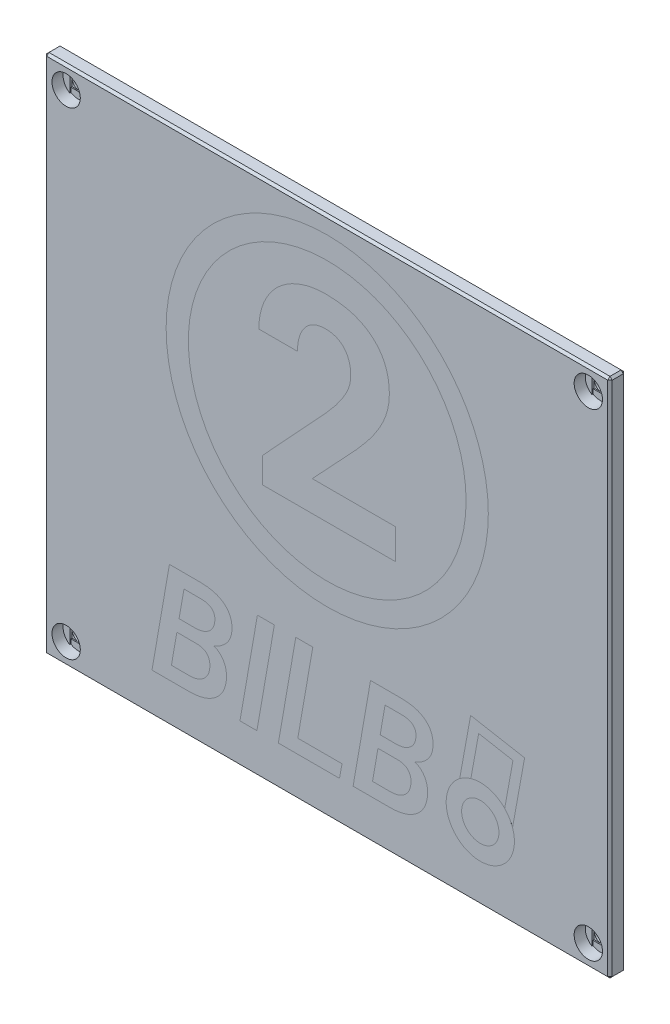
from build123d import *

# Parameters (mm, degrees)
SKETCH2_W               = 101.8
SKETCH2_H               = 93.8
SKETCH2_R               = 1.35
BOSS_EXTRUDE1_DEPTH     = 2.8
SKETCH3_R               = 2.55
CUT_EXTRUDE1_DEPTH      = 2
CUT_EXTRUDE2_DEPTH      = 0.2
SKETCH5_W               = 2.7
SKETCH5_H               = 2.7
CUT_EXTRUDE3_DEPTH      = 0.2
MIRROR2_COPY_1_DEPTH    = 0.2
MIRROR2_COPY_2_SKETCH_W = 2.7
MIRROR2_COPY_2_SKETCH_H = 2.7
MIRROR2_COPY_2_DEPTH    = 0.2
CHAMFER1_SIZE           = 0.4
SKETCH6_W               = 81.8
SKETCH6_H               = 73.8
CUT_EXTRUDE4_DEPTH      = 1.2
SKETCH7_R               = 29
SKETCH7_R_2             = 25
CUT_EXTRUDE5_DEPTH      = 1
SKETCH7_2_R             = 29
SKETCH7_2_R_2           = 25
BOSS_EXTRUDE2_DEPTH     = 1
CUT_EXTRUDE6_DEPTH      = 1
BOSS_EXTRUDE3_DEPTH     = 1
CUT_EXTRUDE7_DEPTH      = 1
BOSS_EXTRUDE4_DEPTH     = 1
BOSS_EXTRUDE4_2_DEPTH   = 1
BOSS_EXTRUDE4_3_DEPTH   = 1
BOSS_EXTRUDE4_4_DEPTH   = 1
BOSS_EXTRUDE4_5_DEPTH   = 1
CUT_EXTRUDE8_DEPTH      = 1
BOSS_EXTRUDE5_DEPTH     = 1


with BuildPart() as part:
    # Sketch2 → Boss-Extrude1 (new body)
    with BuildSketch(Plane.XY):
        with Locations((0, -6)):
            Rectangle(SKETCH2_W, SKETCH2_H)
        with Locations((-47, 37)):
            Circle(SKETCH2_R, mode=Mode.SUBTRACT)
        with Locations((47, 37)):
            Circle(SKETCH2_R, mode=Mode.SUBTRACT)
        with Locations((47, -49)):
            Circle(SKETCH2_R, mode=Mode.SUBTRACT)
        with Locations((-47, -49)):
            Circle(SKETCH2_R, mode=Mode.SUBTRACT)
    extrude(amount=BOSS_EXTRUDE1_DEPTH)

    # Sketch3 → Cut-Extrude1 (cut)
    with BuildSketch(Plane.XY.offset(2.8)):
        with Locations((-47, 37)):
            Circle(SKETCH3_R)
        with Locations((47, 37)):
            Circle(SKETCH3_R)
        with Locations((47, -49)):
            Circle(SKETCH3_R)
        with Locations((-47, -49)):
            Circle(SKETCH3_R)
    extrude(amount=-CUT_EXTRUDE1_DEPTH, mode=Mode.SUBTRACT)

    # Sketch4 → Cut-Extrude2 (cut)
    with BuildSketch(Plane.XY.offset(0.8)):
        with BuildLine():
            Line((-48.35, 34.836669235), (-48.35, 39.163330765))
            ThreePointArc((-48.35, 39.163330765), (-47, 39.55), (-45.65, 39.163330765))
            Line((-45.65, 39.163330765), (-45.65, 34.836669235))
            ThreePointArc((-45.65, 34.836669235), (-47, 34.45), (-48.35, 34.836669235))
        make_face()
    cut_extrude2 = extrude(amount=-CUT_EXTRUDE2_DEPTH, mode=Mode.SUBTRACT)

    # Sketch5 → Cut-Extrude3 (cut)
    with BuildSketch(Plane.XY.offset(0.6)):
        with Locations((-47, 37)):
            Rectangle(SKETCH5_W, SKETCH5_H)
    cut_extrude3 = extrude(amount=-CUT_EXTRUDE3_DEPTH, mode=Mode.SUBTRACT)

    # Mirror1: Cut-Extrude2, Cut-Extrude3 across plane
    add(cut_extrude2.mirror(Plane.ZX.offset(-6)), mode=Mode.SUBTRACT)
    add(cut_extrude3.mirror(Plane.ZX.offset(-6)), mode=Mode.SUBTRACT)

    # Mirror2: Cut-Extrude2, Cut-Extrude3 across plane
    add(cut_extrude2.mirror(Plane(origin=(0, 0, 0), x_dir=(0, 0, 1), z_dir=(1, 0, 0))), mode=Mode.SUBTRACT)
    add(cut_extrude3.mirror(Plane(origin=(0, 0, 0), x_dir=(0, 0, 1), z_dir=(1, 0, 0))), mode=Mode.SUBTRACT)

    # Mirror2 copy 1 sketch → Mirror2 copy 1 (cut)
    with BuildSketch(Plane(origin=(0, -12, 0.8), x_dir=(-1, 0, 0), z_dir=(0, 0, 1))):
        with BuildLine():
            Line((-48.35, 34.836669235), (-48.35, 39.163330765))
            ThreePointArc((-48.35, 39.163330765), (-47, 39.55), (-45.65, 39.163330765))
            Line((-45.65, 39.163330765), (-45.65, 34.836669235))
            ThreePointArc((-45.65, 34.836669235), (-47, 34.45), (-48.35, 34.836669235))
        make_face()
    extrude(amount=-MIRROR2_COPY_1_DEPTH, mode=Mode.SUBTRACT)

    # Mirror2 copy 2 sketch → Mirror2 copy 2 (cut)
    with BuildSketch(Plane(origin=(0, -12, 0.6), x_dir=(-1, 0, 0), z_dir=(0, 0, 1))):
        with Locations((-47, 37)):
            Rectangle(MIRROR2_COPY_2_SKETCH_W, MIRROR2_COPY_2_SKETCH_H)
    extrude(amount=-MIRROR2_COPY_2_DEPTH, mode=Mode.SUBTRACT)

    # Chamfer1
    chamfer1_edges = [part.edges().sort_by_distance(p)[0] for p in [
        (50.9, -6, 2.8),
        (0, 40.9, 2.8),
        (-50.9, -6, 2.8),
        (0, 40.9, 0),
        (50.9, -6, 0),
        (0, -52.9, 0),
        (-50.9, -6, 0),
        (-50.9, 40.9, 1.4),
        (50.9, 40.9, 1.4),
        (50.9, -52.9, 1.4),
        (-50.9, -52.9, 1.4),
        (0, -52.9, 2.8),
    ]]
    chamfer(chamfer1_edges, length=CHAMFER1_SIZE)

    # Sketch6 → Cut-Extrude4 (cut)
    with BuildSketch(Plane(origin=(0, 0, 0), x_dir=(-1, 0, 0), z_dir=(0, 0, -1))):
        with Locations((0, -6)):
            Rectangle(SKETCH6_W, SKETCH6_H)
    extrude(amount=-CUT_EXTRUDE4_DEPTH, mode=Mode.SUBTRACT)

    # Sketch7 → Cut-Extrude5 (cut)
    with BuildSketch(Plane.XY.offset(2.8)):
        with Locations((0, 8.9)):
            Circle(SKETCH7_R)
        with Locations((0, 8.9)):
            Circle(SKETCH7_R_2, mode=Mode.SUBTRACT)
    extrude(amount=-CUT_EXTRUDE5_DEPTH, mode=Mode.SUBTRACT)

    # Sketch8 → Cut-Extrude6 (cut)
    with BuildSketch(Plane.XY.offset(2.8)):
        with BuildLine():
            Line((12.308806818, -6.9), (-11.611647727, -6.9))
            Line((-11.611647727, -6.9), (-11.611647727, -2.262215909))
            Line((-11.611647727, -2.262215909), (-0.319034091, 9.911079545))
            add(Edge.make_bspline(
                [(-0.319034091, 9.911079545), (0.046385124, 10.32500147), (0.741681077, 11.112585228), (1.681474188, 12.275609102), (2.469340925, 13.357130302), (3.111098177, 14.364459395), (3.617475219, 15.319007899), (3.969715632, 16.24865266), (4.187704616, 17.157189298), (4.218527997, 17.758004133), (4.233522727, 18.050284091)],
                knots=[0, 0, 0, 0, 0.001656292, 0.003151485, 0.004484065, 0.005668293, 0.00673245, 0.007719155, 0.00864436, 0.009520822, 0.009520822, 0.009520822, 0.009520822], degree=3))
            add(Edge.make_bspline(
                [(4.233522727, 18.050284091), (4.222002767, 18.42320379), (4.200054171, 19.133715287), (3.977941185, 20.137075527), (3.608226076, 21.018906979), (3.164221923, 21.642288746), (2.758902446, 22.077096009), (2.410135775, 22.348210778), (2.035921266, 22.580076326), (1.6321501, 22.780598295), (1.191202102, 22.913676881), (0.724841328, 23.025059029), (0.224832259, 23.088452989), (-0.1200019, 23.096072798), (-0.297727273, 23.1)],
                knots=[0, 0, 0, 0, 0.001117316, 0.002128786, 0.003064158, 0.003966594, 0.00440865, 0.004843457, 0.00528688, 0.005728423, 0.006191107, 0.006664888, 0.007166139, 0.007699236, 0.007699236, 0.007699236, 0.007699236], degree=3))
            add(Edge.make_bspline(
                [(-0.297727273, 23.1), (-0.489778706, 23.094385488), (-0.863682605, 23.083454626), (-1.408489781, 23.002941766), (-1.920810873, 22.876850677), (-2.403503345, 22.69835886), (-2.854738269, 22.462192091), (-3.271175119, 22.169541221), (-3.662387192, 21.832033134), (-4.013594205, 21.440489579), (-4.333002485, 21.011649874), (-4.602618823, 20.541839399), (-4.841809345, 20.046130428), (-5.020342245, 19.509427426), (-5.173712915, 18.946058662), (-5.277163903, 18.349272526), (-5.343293328, 17.720343597), (-5.350732051, 17.290517497), (-5.354545455, 17.070170455)],
                knots=[0, 0, 0, 0, 0.000575985, 0.001121382, 0.001648484, 0.002156383, 0.002661494, 0.003171772, 0.003680217, 0.004208131, 0.004746501, 0.00528125, 0.005830885, 0.006394656, 0.00697522, 0.007581248, 0.008209509, 0.008870364, 0.008870364, 0.008870364, 0.008870364], degree=3))
            Line((-5.354545455, 17.070170455), (-12.307670455, 17.070170455))
            add(Edge.make_bspline(
                [(-12.307670455, 17.070170455), (-12.291892712, 17.592522347), (-12.260726492, 18.624338799), (-11.953970118, 20.128962544), (-11.487523274, 21.570135071), (-10.817776605, 22.924881667), (-9.97300169, 24.172944223), (-8.972231012, 25.298301174), (-7.797179901, 26.258148805), (-6.712136052, 26.944918404), (-5.777702784, 27.411834126), (-5.044661786, 27.718673693), (-4.288714461, 27.972316034), (-3.512263707, 28.189488487), (-2.709089407, 28.348786663), (-1.884618269, 28.471480562), (-1.037679487, 28.543992965), (-0.465951481, 28.551002629), (-0.176988636, 28.554545455)],
                knots=[0, 0, 0, 0, 0.001565226, 0.003091834, 0.004587634, 0.006099551, 0.007608462, 0.009097164, 0.010600331, 0.012145169, 0.012939227, 0.01373195, 0.014527024, 0.015329958, 0.016148971, 0.016981635, 0.017829784, 0.018696523, 0.018696523, 0.018696523, 0.018696523], degree=3))
            add(Edge.make_bspline(
                [(-0.176988636, 28.554545455), (0.258925877, 28.546352483), (1.108806637, 28.530379055), (2.347484714, 28.406672953), (3.512675121, 28.214264157), (4.601684716, 27.928949402), (5.613934271, 27.558475211), (6.554840249, 27.111834904), (7.422759809, 26.585655483), (8.203914583, 25.969826424), (8.910609806, 25.292365062), (9.519195393, 24.535587481), (10.041143009, 23.718513297), (10.462215987, 22.827474445), (10.78758639, 21.871560544), (11.022980896, 20.851075432), (11.156237975, 19.763087063), (11.176320755, 19.016553262), (11.186647727, 18.632670455)],
                knots=[0, 0, 0, 0, 0.001307513, 0.002549192, 0.003730819, 0.004847119, 0.005921137, 0.00695994, 0.007967287, 0.008958964, 0.009938382, 0.010897846, 0.011865269, 0.012840558, 0.013846778, 0.014889095, 0.015977042, 0.017128684, 0.017128684, 0.017128684, 0.017128684], degree=3))
            add(Edge.make_bspline(
                [(11.186647727, 18.632670455), (11.169260049, 18.198312911), (11.13402119, 17.318019213), (10.872737149, 15.994364547), (10.450398039, 14.658487031), (9.955762844, 13.549073246), (9.479460404, 12.639803325), (9.051740032, 11.922054404), (8.55818677, 11.18115744), (8.020779633, 10.399624193), (7.405931285, 9.604753552), (6.744134003, 8.768513978), (6.023338248, 7.902993521), (5.506777755, 7.328884474), (5.242045455, 7.034659091)],
                knots=[0, 0, 0, 0, 0.001302507, 0.002639735, 0.004032397, 0.005498461, 0.0062768, 0.007111159, 0.008003505, 0.008947252, 0.0099558, 0.011017299, 0.012146717, 0.013334008, 0.013334008, 0.013334008, 0.013334008], degree=3))
            Line((5.242045455, 7.034659091), (-2.691193182, -1.445454545))
            Line((-2.691193182, -1.445454545), (12.308806818, -1.445454545))
            Line((12.308806818, -1.445454545), (12.308806818, -6.9))
        make_face()
    extrude(amount=-CUT_EXTRUDE6_DEPTH, mode=Mode.SUBTRACT)

    # Sketch9 → Cut-Extrude7 (cut)
    with BuildSketch(Plane.XY.offset(2.8)):
        with BuildLine():
            add(Edge.make_bspline(
                [(-20.133559814, -44.28194528), (-21.340720814, -45.24106528), (-22.936488814, -45.72062528), (-24.920863814, -45.72062528)],
                knots=[0, 0, 0, 0, 1, 1, 1, 1], degree=3))
            Line((-24.920863814, -45.72062528), (-31.543715814, -45.72062728))
            Line((-31.543715814, -45.72062728), (-28.405922814, -27.66281228))
            Line((-28.405922814, -27.66281228), (-22.862074814, -27.67521228))
            add(Edge.make_bspline(
                [(-22.862074814, -27.67521228), (-20.910772814, -27.68347928), (-19.447296814, -28.10929228), (-18.471645814, -28.95265328)],
                knots=[0, 0, 0, 0, 1, 1, 1, 1], degree=3))
            add(Edge.make_bspline(
                [(-18.471645814, -28.95265328), (-17.487726814, -29.78774428), (-17.053644814, -30.94943228), (-17.169399814, -32.43771528)],
                knots=[0, 0, 0, 0, 1, 1, 1, 1], degree=3))
            add(Edge.make_bspline(
                [(-17.169399814, -32.43771528), (-17.318227814, -34.19057528), (-18.388963814, -35.50935528), (-20.381606814, -36.39405528)],
                knots=[0, 0, 0, 0, 1, 1, 1, 1], degree=3))
            add(Edge.make_bspline(
                [(-20.381606814, -36.39405528), (-19.637465814, -36.65864228), (-19.062823814, -37.14233528), (-18.657680814, -37.84513528)],
                knots=[0, 0, 0, 0, 1, 1, 1, 1], degree=3))
            add(Edge.make_bspline(
                [(-18.657680814, -37.84513528), (-18.252537814, -38.54793528), (-18.078904814, -39.38715828), (-18.136782814, -40.36280528)],
                knots=[0, 0, 0, 0, 1, 1, 1, 1], degree=3))
            add(Edge.make_bspline(
                [(-18.136782814, -40.36280528), (-18.252537814, -42.01645228), (-18.918129814, -43.32283228), (-20.133559814, -44.28194528)],
                knots=[0, 0, 0, 0, 1, 1, 1, 1], degree=3))
        make_face()
        with BuildLine():
            add(Edge.make_bspline(
                [(-20.257582814, -32.61134728), (-20.050877814, -31.06518828), (-20.832224814, -30.26316928), (-22.601625814, -30.20529228)],
                knots=[0, 0, 0, 0, 1, 1, 1, 1], degree=3))
            Line((-22.601625814, -30.20529228), (-25.789028814, -30.19289228))
            Line((-25.789028814, -30.19289228), (-26.669594814, -35.26544728))
            Line((-26.669594814, -35.26544728), (-23.854262814, -35.27784728))
            add(Edge.make_bspline(
                [(-23.854262814, -35.27784728), (-22.845538814, -35.27784728), (-22.022849814, -35.03807028), (-21.386196814, -34.55851728)],
                knots=[0, 0, 0, 0, 1, 1, 1, 1], degree=3))
            add(Edge.make_bspline(
                [(-21.386196814, -34.55851728), (-20.749542814, -34.07895728), (-20.373337814, -33.42990028), (-20.257582814, -32.61134728)],
                knots=[0, 0, 0, 0, 1, 1, 1, 1], degree=3))
        make_face(mode=Mode.SUBTRACT)
        with BuildLine():
            add(Edge.make_bspline(
                [(-21.547426814, -38.35361728), (-21.919497814, -37.87406428), (-22.535480814, -37.61775028), (-23.395375814, -37.58467728)],
                knots=[0, 0, 0, 0, 1, 1, 1, 1], degree=3))
            Line((-23.395375814, -37.58467728), (-27.066469814, -37.57228728))
            Line((-27.066469814, -37.57228728), (-28.046254814, -43.21534728))
            Line((-28.046254814, -43.21534728), (-24.834047814, -43.22774728))
            add(Edge.make_bspline(
                [(-24.834047814, -43.22774728), (-23.866664814, -43.22774728), (-23.043976814, -42.97143028), (-22.365981814, -42.45879728)],
                knots=[0, 0, 0, 0, 1, 1, 1, 1], degree=3))
            add(Edge.make_bspline(
                [(-22.365981814, -42.45879728), (-21.687986814, -41.94617028), (-21.286977814, -41.24337028), (-21.162953814, -40.35039728)],
                knots=[0, 0, 0, 0, 1, 1, 1, 1], degree=3))
            add(Edge.make_bspline(
                [(-21.162953814, -40.35039728), (-21.047198814, -39.49877028), (-21.175356814, -38.83317728), (-21.547426814, -38.35361728)],
                knots=[0, 0, 0, 0, 1, 1, 1, 1], degree=3))
        make_face(mode=Mode.SUBTRACT)
        Polygon((-9.517153814, -27.66281228), (-12.654946814, -45.72062728), (-15.705922814, -45.72062728), (-12.568129814, -27.66281228), align=None)
        Polygon((-2.596648814, -27.66281228), (-5.300358814, -43.21534728), (2.661951186, -43.21534728), (2.215461186, -45.72062728), (-8.797818814, -45.72062728), (-5.660028814, -27.66281228), align=None)
        with BuildLine():
            add(Edge.make_bspline(
                [(16.068881186, -44.28194528), (14.861721186, -45.24106528), (13.265954186, -45.72062528), (11.281581186, -45.72062528)],
                knots=[0, 0, 0, 0, 1, 1, 1, 1], degree=3))
            Line((11.281581186, -45.72062528), (4.658731186, -45.72062728))
            Line((4.658731186, -45.72062728), (7.796521186, -27.66281228))
            Line((7.796521186, -27.66281228), (13.340371186, -27.67521228))
            add(Edge.make_bspline(
                [(13.340371186, -27.67521228), (15.291671186, -27.68347928), (16.755148186, -28.10929228), (17.730801186, -28.95265328)],
                knots=[0, 0, 0, 0, 1, 1, 1, 1], degree=3))
            add(Edge.make_bspline(
                [(17.730801186, -28.95265328), (18.714714186, -29.78774428), (19.148794186, -30.94943228), (19.033041186, -32.43771528)],
                knots=[0, 0, 0, 0, 1, 1, 1, 1], degree=3))
            add(Edge.make_bspline(
                [(19.033041186, -32.43771528), (18.884214186, -34.19057528), (17.813478186, -35.50935528), (15.820831186, -36.39405528)],
                knots=[0, 0, 0, 0, 1, 1, 1, 1], degree=3))
            add(Edge.make_bspline(
                [(15.820831186, -36.39405528), (16.564978186, -36.65864228), (17.139621186, -37.14233528), (17.544761186, -37.84513528)],
                knots=[0, 0, 0, 0, 1, 1, 1, 1], degree=3))
            add(Edge.make_bspline(
                [(17.544761186, -37.84513528), (17.949908186, -38.54793528), (18.123541186, -39.38715828), (18.065661186, -40.36280528)],
                knots=[0, 0, 0, 0, 1, 1, 1, 1], degree=3))
            add(Edge.make_bspline(
                [(18.065661186, -40.36280528), (17.949908186, -42.01645228), (17.284314186, -43.32283228), (16.068881186, -44.28194528)],
                knots=[0, 0, 0, 0, 1, 1, 1, 1], degree=3))
        make_face()
        with BuildLine():
            add(Edge.make_bspline(
                [(15.944861186, -32.61134728), (16.151568186, -31.06518828), (15.370218186, -30.26316928), (13.600811186, -30.20529228)],
                knots=[0, 0, 0, 0, 1, 1, 1, 1], degree=3))
            Line((13.600811186, -30.20529228), (10.413411186, -30.19289228))
            Line((10.413411186, -30.19289228), (9.532851186, -35.26544728))
            Line((9.532851186, -35.26544728), (12.348181186, -35.27784728))
            add(Edge.make_bspline(
                [(12.348181186, -35.27784728), (13.356901186, -35.27784728), (14.179588186, -35.03807028), (14.816241186, -34.55851728)],
                knots=[0, 0, 0, 0, 1, 1, 1, 1], degree=3))
            add(Edge.make_bspline(
                [(14.816241186, -34.55851728), (15.452901186, -34.07895728), (15.829108186, -33.42990028), (15.944861186, -32.61134728)],
                knots=[0, 0, 0, 0, 1, 1, 1, 1], degree=3))
        make_face(mode=Mode.SUBTRACT)
        with BuildLine():
            add(Edge.make_bspline(
                [(14.655011186, -38.35361728), (14.282944186, -37.87406428), (13.666961186, -37.61775028), (12.807061186, -37.58467728)],
                knots=[0, 0, 0, 0, 1, 1, 1, 1], degree=3))
            Line((12.807061186, -37.58467728), (9.135971186, -37.57228728))
            Line((9.135971186, -37.57228728), (8.156191186, -43.21534728))
            Line((8.156191186, -43.21534728), (11.368391186, -43.22774728))
            add(Edge.make_bspline(
                [(11.368391186, -43.22774728), (12.335778186, -43.22774728), (13.158468186, -42.97143028), (13.836461186, -42.45879728)],
                knots=[0, 0, 0, 0, 1, 1, 1, 1], degree=3))
            add(Edge.make_bspline(
                [(13.836461186, -42.45879728), (14.514454186, -41.94617028), (14.915464186, -41.24337028), (15.039491186, -40.35039728)],
                knots=[0, 0, 0, 0, 1, 1, 1, 1], degree=3))
            add(Edge.make_bspline(
                [(15.039491186, -40.35039728), (15.155244186, -39.49877028), (15.027084186, -38.83317728), (14.655011186, -38.35361728)],
                knots=[0, 0, 0, 0, 1, 1, 1, 1], degree=3))
        make_face(mode=Mode.SUBTRACT)
        with BuildLine():
            add(Edge.make_bspline(
                [(33.697238186, -39.82961728), (33.697238186, -38.20072528), (33.050162186, -36.63854728), (31.898362186, -35.48674628)],
                knots=[0, 0, 0, 0, 1, 1, 1, 1], degree=3))
            add(Edge.make_bspline(
                [(31.898362186, -35.48674628), (30.746561186, -34.33494628), (29.184383186, -33.68787028), (27.555491186, -33.68787028)],
                knots=[0, 0, 0, 0, 1, 1, 1, 1], degree=3))
            add(Edge.make_bspline(
                [(27.555491186, -33.68787028), (25.071386186, -33.68787028), (22.831883186, -35.18425928), (21.881257186, -37.47927228)],
                knots=[0, 0, 0, 0, 1, 1, 1, 1], degree=3))
            add(Edge.make_bspline(
                [(21.881257186, -37.47927228), (20.930631186, -39.77428628), (21.456093186, -42.41596028), (23.212620186, -44.17248828)],
                knots=[0, 0, 0, 0, 1, 1, 1, 1], degree=3))
            add(Edge.make_bspline(
                [(23.212620186, -44.17248828), (24.969148186, -45.92901528), (27.610822186, -46.45447728), (29.905836186, -45.50385128)],
                knots=[0, 0, 0, 0, 1, 1, 1, 1], degree=3))
            add(Edge.make_bspline(
                [(29.905836186, -45.50385128), (32.200849186, -44.55322528), (33.697238186, -42.31372228), (33.697238186, -39.82961728)],
                knots=[0, 0, 0, 0, 1, 1, 1, 1], degree=3))
        make_face()
        with BuildLine():
            add(Edge.make_bspline(
                [(29.932660186, -37.45244828), (29.302195186, -36.82198428), (28.447102186, -36.46779328), (27.555491186, -36.46779328)],
                knots=[0, 0, 0, 0, 1, 1, 1, 1], degree=3))
            add(Edge.make_bspline(
                [(27.555491186, -36.46779328), (26.195760186, -36.46779328), (24.969917186, -37.28687528), (24.449570186, -38.54310328)],
                knots=[0, 0, 0, 0, 1, 1, 1, 1], degree=3))
            add(Edge.make_bspline(
                [(24.449570186, -38.54310328), (23.929224186, -39.79933028), (24.216847186, -41.24531128), (25.178322186, -42.20678628)],
                knots=[0, 0, 0, 0, 1, 1, 1, 1], degree=3))
            add(Edge.make_bspline(
                [(25.178322186, -42.20678628), (26.139797186, -43.16826128), (27.585778186, -43.45588428), (28.842005186, -42.93553828)],
                knots=[0, 0, 0, 0, 1, 1, 1, 1], degree=3))
            add(Edge.make_bspline(
                [(28.842005186, -42.93553828), (30.098233186, -42.41519128), (30.917315186, -41.18934828), (30.917315186, -39.82961728)],
                knots=[0, 0, 0, 0, 1, 1, 1, 1], degree=3))
            add(Edge.make_bspline(
                [(30.917315186, -39.82961728), (30.917315186, -38.93800628), (30.563124186, -38.08291328), (29.932660186, -37.45244828)],
                knots=[0, 0, 0, 0, 1, 1, 1, 1], degree=3))
        make_face(mode=Mode.SUBTRACT)
    extrude(amount=-CUT_EXTRUDE7_DEPTH, mode=Mode.SUBTRACT)

    # Sketch10 → Cut-Extrude8 (cut)
    with BuildSketch(Plane.XY.offset(2.8)):
        with BuildLine():
            Line((35.529593186, -25.86224928), (33.361742565, -37.827481777))
            add(Edge.make_bspline(
                [(33.361742565, -37.827481777), (33.068142523, -36.976090582), (32.588251207, -36.191936535), (31.94752174, -35.536467995)],
                knots=[0.422314756, 0.422314756, 0.422314756, 0.422314756, 0.985683182, 0.985683182, 0.985683182, 0.985683182], degree=3))
            Line((31.94752174, -35.536467995), (33.43753038, -27.312515835))
            Line((33.43753038, -27.312515835), (27.262743774, -26.19377313))
            Line((27.262743774, -26.19377313), (25.861881169, -33.92569283))
            add(Edge.make_bspline(
                [(25.861881169, -33.92569283), (25.131570387, -34.13524271), (24.450098636, -34.477778089), (23.850380245, -34.931306228)],
                knots=[0.234479883, 0.234479883, 0.234479883, 0.234479883, 0.550360789, 0.550360789, 0.550360789, 0.550360789], degree=3))
            Line((23.850380245, -34.931306228), (25.812477186, -24.10171028))
            Line((25.812477186, -24.10171028), (35.529593186, -25.86224928))
        make_face()
    extrude(amount=-CUT_EXTRUDE8_DEPTH, mode=Mode.SUBTRACT)


with BuildPart() as body_2:
    # Sketch7_2 → Boss-Extrude2 (new body)
    with BuildSketch(Plane.XY.offset(2.8)):
        with Locations((0, 8.9)):
            Circle(SKETCH7_2_R)
        with Locations((0, 8.9)):
            Circle(SKETCH7_2_R_2, mode=Mode.SUBTRACT)
    extrude(amount=-BOSS_EXTRUDE2_DEPTH)


with BuildPart() as body_3:
    # Sketch8_2 → Boss-Extrude3 (new body)
    with BuildSketch(Plane.XY.offset(2.8)):
        with BuildLine():
            Line((12.308806818, -6.9), (-11.611647727, -6.9))
            Line((-11.611647727, -6.9), (-11.611647727, -2.262215909))
            Line((-11.611647727, -2.262215909), (-0.319034091, 9.911079545))
            add(Edge.make_bspline(
                [(-0.319034091, 9.911079545), (0.046385124, 10.32500147), (0.741681077, 11.112585228), (1.681474188, 12.275609102), (2.469340925, 13.357130302), (3.111098177, 14.364459395), (3.617475219, 15.319007899), (3.969715632, 16.24865266), (4.187704616, 17.157189298), (4.218527997, 17.758004133), (4.233522727, 18.050284091)],
                knots=[0, 0, 0, 0, 0.001656292, 0.003151485, 0.004484065, 0.005668293, 0.00673245, 0.007719155, 0.00864436, 0.009520822, 0.009520822, 0.009520822, 0.009520822], degree=3))
            add(Edge.make_bspline(
                [(4.233522727, 18.050284091), (4.222002767, 18.42320379), (4.200054171, 19.133715287), (3.977941185, 20.137075527), (3.608226076, 21.018906979), (3.164221923, 21.642288746), (2.758902446, 22.077096009), (2.410135775, 22.348210778), (2.035921266, 22.580076326), (1.6321501, 22.780598295), (1.191202102, 22.913676881), (0.724841328, 23.025059029), (0.224832259, 23.088452989), (-0.1200019, 23.096072798), (-0.297727273, 23.1)],
                knots=[0, 0, 0, 0, 0.001117316, 0.002128786, 0.003064158, 0.003966594, 0.00440865, 0.004843457, 0.00528688, 0.005728423, 0.006191107, 0.006664888, 0.007166139, 0.007699236, 0.007699236, 0.007699236, 0.007699236], degree=3))
            add(Edge.make_bspline(
                [(-0.297727273, 23.1), (-0.489778706, 23.094385488), (-0.863682605, 23.083454626), (-1.408489781, 23.002941766), (-1.920810873, 22.876850677), (-2.403503345, 22.69835886), (-2.854738269, 22.462192091), (-3.271175119, 22.169541221), (-3.662387192, 21.832033134), (-4.013594205, 21.440489579), (-4.333002485, 21.011649874), (-4.602618823, 20.541839399), (-4.841809345, 20.046130428), (-5.020342245, 19.509427426), (-5.173712915, 18.946058662), (-5.277163903, 18.349272526), (-5.343293328, 17.720343597), (-5.350732051, 17.290517497), (-5.354545455, 17.070170455)],
                knots=[0, 0, 0, 0, 0.000575985, 0.001121382, 0.001648484, 0.002156383, 0.002661494, 0.003171772, 0.003680217, 0.004208131, 0.004746501, 0.00528125, 0.005830885, 0.006394656, 0.00697522, 0.007581248, 0.008209509, 0.008870364, 0.008870364, 0.008870364, 0.008870364], degree=3))
            Line((-5.354545455, 17.070170455), (-12.307670455, 17.070170455))
            add(Edge.make_bspline(
                [(-12.307670455, 17.070170455), (-12.291892712, 17.592522347), (-12.260726492, 18.624338799), (-11.953970118, 20.128962544), (-11.487523274, 21.570135071), (-10.817776605, 22.924881667), (-9.97300169, 24.172944223), (-8.972231012, 25.298301174), (-7.797179901, 26.258148805), (-6.712136052, 26.944918404), (-5.777702784, 27.411834126), (-5.044661786, 27.718673693), (-4.288714461, 27.972316034), (-3.512263707, 28.189488487), (-2.709089407, 28.348786663), (-1.884618269, 28.471480562), (-1.037679487, 28.543992965), (-0.465951481, 28.551002629), (-0.176988636, 28.554545455)],
                knots=[0, 0, 0, 0, 0.001565226, 0.003091834, 0.004587634, 0.006099551, 0.007608462, 0.009097164, 0.010600331, 0.012145169, 0.012939227, 0.01373195, 0.014527024, 0.015329958, 0.016148971, 0.016981635, 0.017829784, 0.018696523, 0.018696523, 0.018696523, 0.018696523], degree=3))
            add(Edge.make_bspline(
                [(-0.176988636, 28.554545455), (0.258925877, 28.546352483), (1.108806637, 28.530379055), (2.347484714, 28.406672953), (3.512675121, 28.214264157), (4.601684716, 27.928949402), (5.613934271, 27.558475211), (6.554840249, 27.111834904), (7.422759809, 26.585655483), (8.203914583, 25.969826424), (8.910609806, 25.292365062), (9.519195393, 24.535587481), (10.041143009, 23.718513297), (10.462215987, 22.827474445), (10.78758639, 21.871560544), (11.022980896, 20.851075432), (11.156237975, 19.763087063), (11.176320755, 19.016553262), (11.186647727, 18.632670455)],
                knots=[0, 0, 0, 0, 0.001307513, 0.002549192, 0.003730819, 0.004847119, 0.005921137, 0.00695994, 0.007967287, 0.008958964, 0.009938382, 0.010897846, 0.011865269, 0.012840558, 0.013846778, 0.014889095, 0.015977042, 0.017128684, 0.017128684, 0.017128684, 0.017128684], degree=3))
            add(Edge.make_bspline(
                [(11.186647727, 18.632670455), (11.169260049, 18.198312911), (11.13402119, 17.318019213), (10.872737149, 15.994364547), (10.450398039, 14.658487031), (9.955762844, 13.549073246), (9.479460404, 12.639803325), (9.051740032, 11.922054404), (8.55818677, 11.18115744), (8.020779633, 10.399624193), (7.405931285, 9.604753552), (6.744134003, 8.768513978), (6.023338248, 7.902993521), (5.506777755, 7.328884474), (5.242045455, 7.034659091)],
                knots=[0, 0, 0, 0, 0.001302507, 0.002639735, 0.004032397, 0.005498461, 0.0062768, 0.007111159, 0.008003505, 0.008947252, 0.0099558, 0.011017299, 0.012146717, 0.013334008, 0.013334008, 0.013334008, 0.013334008], degree=3))
            Line((5.242045455, 7.034659091), (-2.691193182, -1.445454545))
            Line((-2.691193182, -1.445454545), (12.308806818, -1.445454545))
            Line((12.308806818, -1.445454545), (12.308806818, -6.9))
        make_face()
    extrude(amount=-BOSS_EXTRUDE3_DEPTH)


with BuildPart() as body_4:
    # Sketch9_5 → Boss-Extrude4 (new body)
    with BuildSketch(Plane.XY.offset(2.8)):
        with BuildLine():
            add(Edge.make_bspline(
                [(-20.133559814, -44.28194528), (-21.340720814, -45.24106528), (-22.936488814, -45.72062528), (-24.920863814, -45.72062528)],
                knots=[0, 0, 0, 0, 1, 1, 1, 1], degree=3))
            Line((-24.920863814, -45.72062528), (-31.543715814, -45.72062728))
            Line((-31.543715814, -45.72062728), (-28.405922814, -27.66281228))
            Line((-28.405922814, -27.66281228), (-22.862074814, -27.67521228))
            add(Edge.make_bspline(
                [(-22.862074814, -27.67521228), (-20.910772814, -27.68347928), (-19.447296814, -28.10929228), (-18.471645814, -28.95265328)],
                knots=[0, 0, 0, 0, 1, 1, 1, 1], degree=3))
            add(Edge.make_bspline(
                [(-18.471645814, -28.95265328), (-17.487726814, -29.78774428), (-17.053644814, -30.94943228), (-17.169399814, -32.43771528)],
                knots=[0, 0, 0, 0, 1, 1, 1, 1], degree=3))
            add(Edge.make_bspline(
                [(-17.169399814, -32.43771528), (-17.318227814, -34.19057528), (-18.388963814, -35.50935528), (-20.381606814, -36.39405528)],
                knots=[0, 0, 0, 0, 1, 1, 1, 1], degree=3))
            add(Edge.make_bspline(
                [(-20.381606814, -36.39405528), (-19.637465814, -36.65864228), (-19.062823814, -37.14233528), (-18.657680814, -37.84513528)],
                knots=[0, 0, 0, 0, 1, 1, 1, 1], degree=3))
            add(Edge.make_bspline(
                [(-18.657680814, -37.84513528), (-18.252537814, -38.54793528), (-18.078904814, -39.38715828), (-18.136782814, -40.36280528)],
                knots=[0, 0, 0, 0, 1, 1, 1, 1], degree=3))
            add(Edge.make_bspline(
                [(-18.136782814, -40.36280528), (-18.252537814, -42.01645228), (-18.918129814, -43.32283228), (-20.133559814, -44.28194528)],
                knots=[0, 0, 0, 0, 1, 1, 1, 1], degree=3))
        make_face()
        with BuildLine():
            add(Edge.make_bspline(
                [(-20.257582814, -32.61134728), (-20.050877814, -31.06518828), (-20.832224814, -30.26316928), (-22.601625814, -30.20529228)],
                knots=[0, 0, 0, 0, 1, 1, 1, 1], degree=3))
            Line((-22.601625814, -30.20529228), (-25.789028814, -30.19289228))
            Line((-25.789028814, -30.19289228), (-26.669594814, -35.26544728))
            Line((-26.669594814, -35.26544728), (-23.854262814, -35.27784728))
            add(Edge.make_bspline(
                [(-23.854262814, -35.27784728), (-22.845538814, -35.27784728), (-22.022849814, -35.03807028), (-21.386196814, -34.55851728)],
                knots=[0, 0, 0, 0, 1, 1, 1, 1], degree=3))
            add(Edge.make_bspline(
                [(-21.386196814, -34.55851728), (-20.749542814, -34.07895728), (-20.373337814, -33.42990028), (-20.257582814, -32.61134728)],
                knots=[0, 0, 0, 0, 1, 1, 1, 1], degree=3))
        make_face(mode=Mode.SUBTRACT)
        with BuildLine():
            add(Edge.make_bspline(
                [(-21.547426814, -38.35361728), (-21.919497814, -37.87406428), (-22.535480814, -37.61775028), (-23.395375814, -37.58467728)],
                knots=[0, 0, 0, 0, 1, 1, 1, 1], degree=3))
            Line((-23.395375814, -37.58467728), (-27.066469814, -37.57228728))
            Line((-27.066469814, -37.57228728), (-28.046254814, -43.21534728))
            Line((-28.046254814, -43.21534728), (-24.834047814, -43.22774728))
            add(Edge.make_bspline(
                [(-24.834047814, -43.22774728), (-23.866664814, -43.22774728), (-23.043976814, -42.97143028), (-22.365981814, -42.45879728)],
                knots=[0, 0, 0, 0, 1, 1, 1, 1], degree=3))
            add(Edge.make_bspline(
                [(-22.365981814, -42.45879728), (-21.687986814, -41.94617028), (-21.286977814, -41.24337028), (-21.162953814, -40.35039728)],
                knots=[0, 0, 0, 0, 1, 1, 1, 1], degree=3))
            add(Edge.make_bspline(
                [(-21.162953814, -40.35039728), (-21.047198814, -39.49877028), (-21.175356814, -38.83317728), (-21.547426814, -38.35361728)],
                knots=[0, 0, 0, 0, 1, 1, 1, 1], degree=3))
        make_face(mode=Mode.SUBTRACT)
    extrude(amount=-BOSS_EXTRUDE4_DEPTH)


with BuildPart() as body_5:
    # Sketch9_5 → Boss-Extrude4 2 (new body)
    with BuildSketch(Plane.XY.offset(2.8)):
        Polygon((-9.517153814, -27.66281228), (-12.654946814, -45.72062728), (-15.705922814, -45.72062728), (-12.568129814, -27.66281228), align=None)
    extrude(amount=-BOSS_EXTRUDE4_2_DEPTH)


with BuildPart() as body_6:
    # Sketch9_5 → Boss-Extrude4 3 (new body)
    with BuildSketch(Plane.XY.offset(2.8)):
        Polygon((-2.596648814, -27.66281228), (-5.300358814, -43.21534728), (2.661951186, -43.21534728), (2.215461186, -45.72062728), (-8.797818814, -45.72062728), (-5.660028814, -27.66281228), align=None)
    extrude(amount=-BOSS_EXTRUDE4_3_DEPTH)


with BuildPart() as body_7:
    # Sketch9_5 → Boss-Extrude4 4 (new body)
    with BuildSketch(Plane.XY.offset(2.8)):
        with BuildLine():
            add(Edge.make_bspline(
                [(16.068881186, -44.28194528), (14.861721186, -45.24106528), (13.265954186, -45.72062528), (11.281581186, -45.72062528)],
                knots=[0, 0, 0, 0, 1, 1, 1, 1], degree=3))
            Line((11.281581186, -45.72062528), (4.658731186, -45.72062728))
            Line((4.658731186, -45.72062728), (7.796521186, -27.66281228))
            Line((7.796521186, -27.66281228), (13.340371186, -27.67521228))
            add(Edge.make_bspline(
                [(13.340371186, -27.67521228), (15.291671186, -27.68347928), (16.755148186, -28.10929228), (17.730801186, -28.95265328)],
                knots=[0, 0, 0, 0, 1, 1, 1, 1], degree=3))
            add(Edge.make_bspline(
                [(17.730801186, -28.95265328), (18.714714186, -29.78774428), (19.148794186, -30.94943228), (19.033041186, -32.43771528)],
                knots=[0, 0, 0, 0, 1, 1, 1, 1], degree=3))
            add(Edge.make_bspline(
                [(19.033041186, -32.43771528), (18.884214186, -34.19057528), (17.813478186, -35.50935528), (15.820831186, -36.39405528)],
                knots=[0, 0, 0, 0, 1, 1, 1, 1], degree=3))
            add(Edge.make_bspline(
                [(15.820831186, -36.39405528), (16.564978186, -36.65864228), (17.139621186, -37.14233528), (17.544761186, -37.84513528)],
                knots=[0, 0, 0, 0, 1, 1, 1, 1], degree=3))
            add(Edge.make_bspline(
                [(17.544761186, -37.84513528), (17.949908186, -38.54793528), (18.123541186, -39.38715828), (18.065661186, -40.36280528)],
                knots=[0, 0, 0, 0, 1, 1, 1, 1], degree=3))
            add(Edge.make_bspline(
                [(18.065661186, -40.36280528), (17.949908186, -42.01645228), (17.284314186, -43.32283228), (16.068881186, -44.28194528)],
                knots=[0, 0, 0, 0, 1, 1, 1, 1], degree=3))
        make_face()
        with BuildLine():
            add(Edge.make_bspline(
                [(15.944861186, -32.61134728), (16.151568186, -31.06518828), (15.370218186, -30.26316928), (13.600811186, -30.20529228)],
                knots=[0, 0, 0, 0, 1, 1, 1, 1], degree=3))
            Line((13.600811186, -30.20529228), (10.413411186, -30.19289228))
            Line((10.413411186, -30.19289228), (9.532851186, -35.26544728))
            Line((9.532851186, -35.26544728), (12.348181186, -35.27784728))
            add(Edge.make_bspline(
                [(12.348181186, -35.27784728), (13.356901186, -35.27784728), (14.179588186, -35.03807028), (14.816241186, -34.55851728)],
                knots=[0, 0, 0, 0, 1, 1, 1, 1], degree=3))
            add(Edge.make_bspline(
                [(14.816241186, -34.55851728), (15.452901186, -34.07895728), (15.829108186, -33.42990028), (15.944861186, -32.61134728)],
                knots=[0, 0, 0, 0, 1, 1, 1, 1], degree=3))
        make_face(mode=Mode.SUBTRACT)
        with BuildLine():
            add(Edge.make_bspline(
                [(14.655011186, -38.35361728), (14.282944186, -37.87406428), (13.666961186, -37.61775028), (12.807061186, -37.58467728)],
                knots=[0, 0, 0, 0, 1, 1, 1, 1], degree=3))
            Line((12.807061186, -37.58467728), (9.135971186, -37.57228728))
            Line((9.135971186, -37.57228728), (8.156191186, -43.21534728))
            Line((8.156191186, -43.21534728), (11.368391186, -43.22774728))
            add(Edge.make_bspline(
                [(11.368391186, -43.22774728), (12.335778186, -43.22774728), (13.158468186, -42.97143028), (13.836461186, -42.45879728)],
                knots=[0, 0, 0, 0, 1, 1, 1, 1], degree=3))
            add(Edge.make_bspline(
                [(13.836461186, -42.45879728), (14.514454186, -41.94617028), (14.915464186, -41.24337028), (15.039491186, -40.35039728)],
                knots=[0, 0, 0, 0, 1, 1, 1, 1], degree=3))
            add(Edge.make_bspline(
                [(15.039491186, -40.35039728), (15.155244186, -39.49877028), (15.027084186, -38.83317728), (14.655011186, -38.35361728)],
                knots=[0, 0, 0, 0, 1, 1, 1, 1], degree=3))
        make_face(mode=Mode.SUBTRACT)
    extrude(amount=-BOSS_EXTRUDE4_4_DEPTH)


with BuildPart() as body_8:
    # Sketch9_5 → Boss-Extrude4 5 (new body)
    with BuildSketch(Plane.XY.offset(2.8)):
        with BuildLine():
            add(Edge.make_bspline(
                [(33.697238186, -39.82961728), (33.697238186, -38.20072528), (33.050162186, -36.63854728), (31.898362186, -35.48674628)],
                knots=[0, 0, 0, 0, 1, 1, 1, 1], degree=3))
            add(Edge.make_bspline(
                [(31.898362186, -35.48674628), (30.746561186, -34.33494628), (29.184383186, -33.68787028), (27.555491186, -33.68787028)],
                knots=[0, 0, 0, 0, 1, 1, 1, 1], degree=3))
            add(Edge.make_bspline(
                [(27.555491186, -33.68787028), (25.071386186, -33.68787028), (22.831883186, -35.18425928), (21.881257186, -37.47927228)],
                knots=[0, 0, 0, 0, 1, 1, 1, 1], degree=3))
            add(Edge.make_bspline(
                [(21.881257186, -37.47927228), (20.930631186, -39.77428628), (21.456093186, -42.41596028), (23.212620186, -44.17248828)],
                knots=[0, 0, 0, 0, 1, 1, 1, 1], degree=3))
            add(Edge.make_bspline(
                [(23.212620186, -44.17248828), (24.969148186, -45.92901528), (27.610822186, -46.45447728), (29.905836186, -45.50385128)],
                knots=[0, 0, 0, 0, 1, 1, 1, 1], degree=3))
            add(Edge.make_bspline(
                [(29.905836186, -45.50385128), (32.200849186, -44.55322528), (33.697238186, -42.31372228), (33.697238186, -39.82961728)],
                knots=[0, 0, 0, 0, 1, 1, 1, 1], degree=3))
        make_face()
        with BuildLine():
            add(Edge.make_bspline(
                [(29.932660186, -37.45244828), (29.302195186, -36.82198428), (28.447102186, -36.46779328), (27.555491186, -36.46779328)],
                knots=[0, 0, 0, 0, 1, 1, 1, 1], degree=3))
            add(Edge.make_bspline(
                [(27.555491186, -36.46779328), (26.195760186, -36.46779328), (24.969917186, -37.28687528), (24.449570186, -38.54310328)],
                knots=[0, 0, 0, 0, 1, 1, 1, 1], degree=3))
            add(Edge.make_bspline(
                [(24.449570186, -38.54310328), (23.929224186, -39.79933028), (24.216847186, -41.24531128), (25.178322186, -42.20678628)],
                knots=[0, 0, 0, 0, 1, 1, 1, 1], degree=3))
            add(Edge.make_bspline(
                [(25.178322186, -42.20678628), (26.139797186, -43.16826128), (27.585778186, -43.45588428), (28.842005186, -42.93553828)],
                knots=[0, 0, 0, 0, 1, 1, 1, 1], degree=3))
            add(Edge.make_bspline(
                [(28.842005186, -42.93553828), (30.098233186, -42.41519128), (30.917315186, -41.18934828), (30.917315186, -39.82961728)],
                knots=[0, 0, 0, 0, 1, 1, 1, 1], degree=3))
            add(Edge.make_bspline(
                [(30.917315186, -39.82961728), (30.917315186, -38.93800628), (30.563124186, -38.08291328), (29.932660186, -37.45244828)],
                knots=[0, 0, 0, 0, 1, 1, 1, 1], degree=3))
        make_face(mode=Mode.SUBTRACT)
    extrude(amount=-BOSS_EXTRUDE4_5_DEPTH)


with BuildPart() as body_9:
    # Sketch10_2 → Boss-Extrude5 (new body)
    with BuildSketch(Plane.XY.offset(2.8)):
        with BuildLine():
            Line((35.529593186, -25.86224928), (33.361742565, -37.827481777))
            add(Edge.make_bspline(
                [(33.361742565, -37.827481777), (33.068142523, -36.976090582), (32.588251207, -36.191936535), (31.94752174, -35.536467995)],
                knots=[0.422314756, 0.422314756, 0.422314756, 0.422314756, 0.985683182, 0.985683182, 0.985683182, 0.985683182], degree=3))
            Line((31.94752174, -35.536467995), (33.43753038, -27.312515835))
            Line((33.43753038, -27.312515835), (27.262743774, -26.19377313))
            Line((27.262743774, -26.19377313), (25.861881169, -33.92569283))
            add(Edge.make_bspline(
                [(25.861881169, -33.92569283), (25.131570387, -34.13524271), (24.450098636, -34.477778089), (23.850380245, -34.931306228)],
                knots=[0.234479883, 0.234479883, 0.234479883, 0.234479883, 0.550360789, 0.550360789, 0.550360789, 0.550360789], degree=3))
            Line((23.850380245, -34.931306228), (25.812477186, -24.10171028))
            Line((25.812477186, -24.10171028), (35.529593186, -25.86224928))
        make_face()
    extrude(amount=-BOSS_EXTRUDE5_DEPTH)


solid = Compound([part.part, body_2.part, body_3.part, body_4.part, body_5.part, body_6.part, body_7.part, body_8.part, body_9.part])
